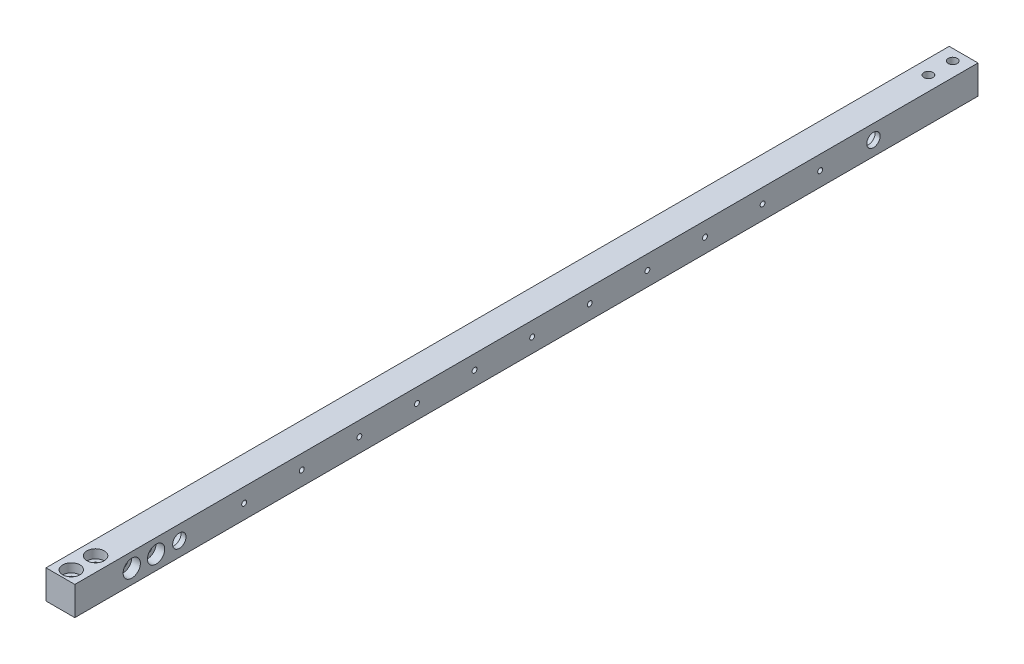
from build123d import *

# Parameters (mm, degrees)
SKETCH1_W                                       = 15.875
SKETCH1_H                                       = 15.875
BOSS_EXTRUDE1_DEPTH                             = 497.84
SKETCH8_R                                       = 6.8199
CUT_EXTRUDE1_DEPTH                              = 13.08862
L_0_29_DIAMETER_HOLE1_D                         = 7.366
L_0_29_DIAMETER_HOLE1_DEPTH                     = 50.8
L_0_29_DIAMETER_HOLE1_TIP                       = 2.21296966
TAP_DRILL_FOR_6_32_TAP1_D                       = 2.7051
CBORE_FOR_10_SOCKET_HEAD_CAP_SCREW3_D           = 4.9784
CBORE_FOR_10_SOCKET_HEAD_CAP_SCREW3_DEPTH       = 25.4
CBORE_FOR_10_SOCKET_HEAD_CAP_SCREW3_CBORE_D     = 9.525
CBORE_FOR_10_SOCKET_HEAD_CAP_SCREW3_CBORE_DEPTH = 4.826
CBORE_FOR_10_SOCKET_HEAD_CAP_SCREW3_TIP         = 1.495662253
CBORE_FOR_10_SOCKET_HEAD_CAP_SCREW2_D           = 4.9784
CBORE_FOR_10_SOCKET_HEAD_CAP_SCREW2_DEPTH       = 25.4
CBORE_FOR_10_SOCKET_HEAD_CAP_SCREW2_CBORE_D     = 9.525
CBORE_FOR_10_SOCKET_HEAD_CAP_SCREW2_CBORE_DEPTH = 4.826
CBORE_FOR_10_SOCKET_HEAD_CAP_SCREW2_TIP         = 1.495662253
CBORE_FOR_10_SOCKET_HEAD_CAP_SCREW1_D           = 4.9784
CBORE_FOR_10_SOCKET_HEAD_CAP_SCREW1_DEPTH       = 25.4
CBORE_FOR_10_SOCKET_HEAD_CAP_SCREW1_CBORE_D     = 9.525
CBORE_FOR_10_SOCKET_HEAD_CAP_SCREW1_CBORE_DEPTH = 4.826
CBORE_FOR_10_SOCKET_HEAD_CAP_SCREW1_TIP         = 1.495662253


with BuildPart() as part:
    # Sketch1 → Boss-Extrude1 (new body)
    with BuildSketch(Plane.XY):
        with Locations((7.9375, 7.9375)):
            Rectangle(SKETCH1_W, SKETCH1_H)
    extrude(amount=BOSS_EXTRUDE1_DEPTH)

    # Sketch8 → Cut-Extrude1 (cut)
    with BuildSketch(Plane.ZY):
        with Locations((440.2201, 7.9375)):
            Circle(SKETCH8_R)
        with Locations((57.6199, 7.9375)):
            Circle(SKETCH8_R)
    extrude(amount=-CUT_EXTRUDE1_DEPTH, mode=Mode.SUBTRACT)

    # L (0.29) Diameter Hole1
    with Locations(Plane.ZY.offset(-13.08862)):
        with Locations((57.6199, 7.9375), (440.2201, 7.9375)):
            Hole(L_0_29_DIAMETER_HOLE1_D / 2, depth=L_0_29_DIAMETER_HOLE1_DEPTH)
            with Locations((0, 0, -(L_0_29_DIAMETER_HOLE1_DEPTH + L_0_29_DIAMETER_HOLE1_TIP / 2))):  # 118° drill point
                Cone(0, L_0_29_DIAMETER_HOLE1_D / 2, L_0_29_DIAMETER_HOLE1_TIP, mode=Mode.SUBTRACT)

    # Tap Drill for #6-32 Tap1 (through all)
    with Locations(Plane(origin=(17.4625, -1824.369207037, -1707.973131805), x_dir=(0, 0, -1), z_dir=(1, 0, 0))):
        with Locations((-2112.468131805, 1832.306707037), (-2080.718131805, 1832.306707037), (-2048.968131805, 1832.306707037), (-2017.218131805, 1832.306707037), (-1985.468131805, 1832.306707037), (-1953.718131805, 1832.306707037), (-1921.968131805, 1832.306707037), (-1890.218131805, 1832.306707037), (-1858.468131805, 1832.306707037), (-1826.718131805, 1832.306707037), (-1794.968131805, 1832.306707037)):
            Hole(TAP_DRILL_FOR_6_32_TAP1_D / 2)

    # CBORE for #10 Socket Head Cap Screw3
    with Locations(Plane(origin=(-863.724136144, 15.875, -1707.973131805), x_dir=(1, 0, 0), z_dir=(0, 1, 0))):
        with Locations((871.661636144, -2186.413131805), (871.661636144, -2199.813131805), (404.936636144, -2186.413131805), (404.936636144, -2199.813131805)):
            CounterBoreHole(CBORE_FOR_10_SOCKET_HEAD_CAP_SCREW3_D / 2, CBORE_FOR_10_SOCKET_HEAD_CAP_SCREW3_CBORE_D / 2, CBORE_FOR_10_SOCKET_HEAD_CAP_SCREW3_CBORE_DEPTH, depth=CBORE_FOR_10_SOCKET_HEAD_CAP_SCREW3_DEPTH)
            with Locations((0, 0, -(CBORE_FOR_10_SOCKET_HEAD_CAP_SCREW3_DEPTH + CBORE_FOR_10_SOCKET_HEAD_CAP_SCREW3_TIP / 2))):  # 118° drill point
                Cone(0, CBORE_FOR_10_SOCKET_HEAD_CAP_SCREW3_D / 2, CBORE_FOR_10_SOCKET_HEAD_CAP_SCREW3_TIP, mode=Mode.SUBTRACT)

    # CBORE for #10 Socket Head Cap Screw2
    with Locations(Plane(origin=(-863.724136144, 0, -1707.973131805), x_dir=(-1, 0, 0), z_dir=(0, -1, 0))):
        with Locations((-404.936636144, -1727.373131805), (-404.936636144, -1713.973131805), (-871.661636144, -1727.373131805), (-871.661636144, -1713.973131805)):
            CounterBoreHole(CBORE_FOR_10_SOCKET_HEAD_CAP_SCREW2_D / 2, CBORE_FOR_10_SOCKET_HEAD_CAP_SCREW2_CBORE_D / 2, CBORE_FOR_10_SOCKET_HEAD_CAP_SCREW2_CBORE_DEPTH, depth=CBORE_FOR_10_SOCKET_HEAD_CAP_SCREW2_DEPTH)
            with Locations((0, 0, -(CBORE_FOR_10_SOCKET_HEAD_CAP_SCREW2_DEPTH + CBORE_FOR_10_SOCKET_HEAD_CAP_SCREW2_TIP / 2))):  # 118° drill point
                Cone(0, CBORE_FOR_10_SOCKET_HEAD_CAP_SCREW2_D / 2, CBORE_FOR_10_SOCKET_HEAD_CAP_SCREW2_TIP, mode=Mode.SUBTRACT)

    # CBORE for #10 Socket Head Cap Screw1
    with Locations(Plane(origin=(15.875, -1686.17948625, -1707.973131805), x_dir=(0, 0, -1), z_dir=(1, 0, 0))):
        with Locations((-2161.013131805, 1694.11698625), (-2174.413131805, 1694.11698625)):
            CounterBoreHole(CBORE_FOR_10_SOCKET_HEAD_CAP_SCREW1_D / 2, CBORE_FOR_10_SOCKET_HEAD_CAP_SCREW1_CBORE_D / 2, CBORE_FOR_10_SOCKET_HEAD_CAP_SCREW1_CBORE_DEPTH, depth=CBORE_FOR_10_SOCKET_HEAD_CAP_SCREW1_DEPTH)
            with Locations((0, 0, -(CBORE_FOR_10_SOCKET_HEAD_CAP_SCREW1_DEPTH + CBORE_FOR_10_SOCKET_HEAD_CAP_SCREW1_TIP / 2))):  # 118° drill point
                Cone(0, CBORE_FOR_10_SOCKET_HEAD_CAP_SCREW1_D / 2, CBORE_FOR_10_SOCKET_HEAD_CAP_SCREW1_TIP, mode=Mode.SUBTRACT)


solid = part.part
